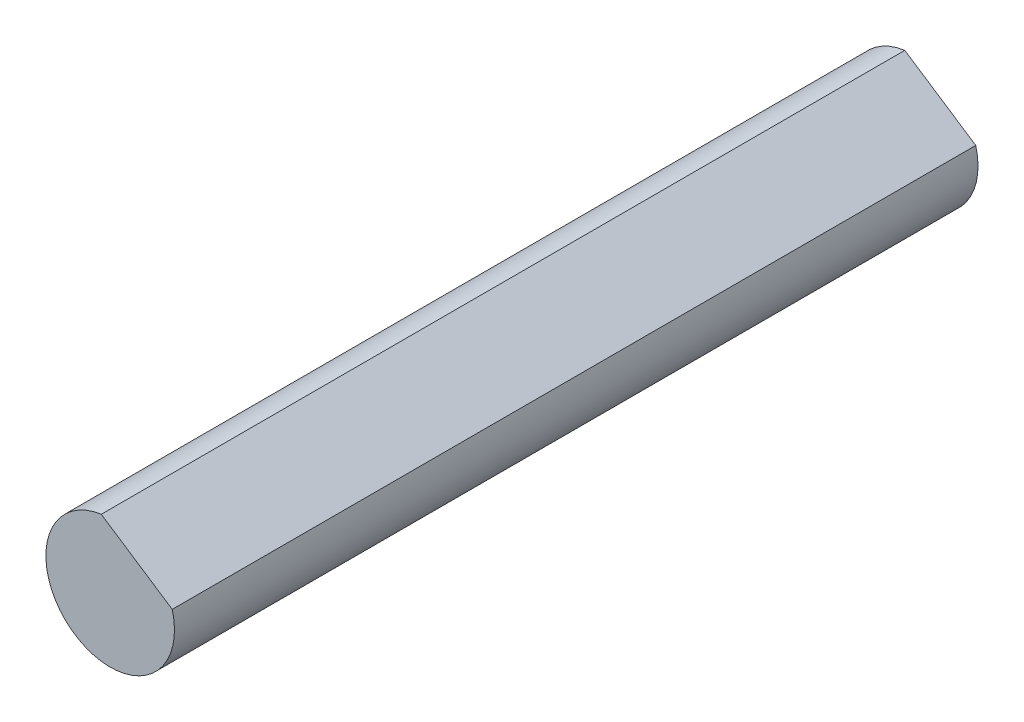
from build123d import *

# Parameters (mm, degrees)
BOSS_EXTRUDE1_DEPTH = 25


with BuildPart() as part:
    # Sketch1 → Boss-Extrude1 (new body)
    with BuildSketch(Plane.XY):
        with BuildLine():
            Line((-0.277203518, 1.980696395), (1.930510842, 0.522616389))
            ThreePointArc((1.930510842, 0.522616389), (-1.102204882, -1.668875189), (-0.277203518, 1.980696395))
        make_face()
    extrude(amount=BOSS_EXTRUDE1_DEPTH)


solid = part.part
